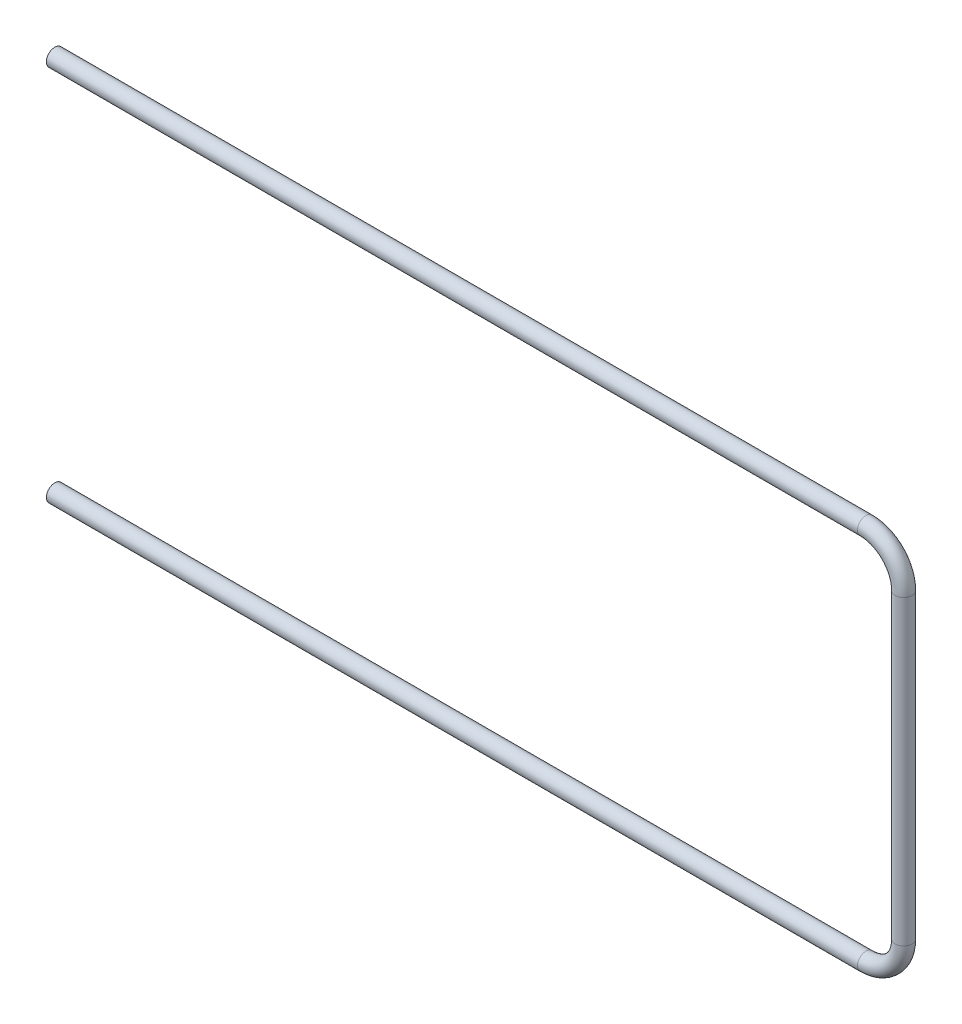
from build123d import *

# Parameters (mm, degrees)
SKETCH1_R   = 4.5
SKETCH1_R_2 = 2.5


with BuildPart() as part:
    # Sweep1: sweep along a path in Sketch2
    with BuildLine(Plane.XY) as sweep1_path:
        Line((0, 0), (430, 0))
        ThreePointArc((430, 0), (444.142135624, -5.857864376), (450, -20))
        Line((450, -20), (450, -180))
        ThreePointArc((450, -180), (444.142135624, -194.142135624), (430, -200))
        Line((430, -200), (0, -200))
    # Sketch1 → Sweep1 (sweep)
    with BuildSketch(Plane(origin=(0, 0, 0), x_dir=(0, 0, -1), z_dir=(1, 0, 0))):
        Circle(SKETCH1_R)
        Circle(SKETCH1_R_2, mode=Mode.SUBTRACT)
    sweep(path=sweep1_path.line)


solid = part.part
